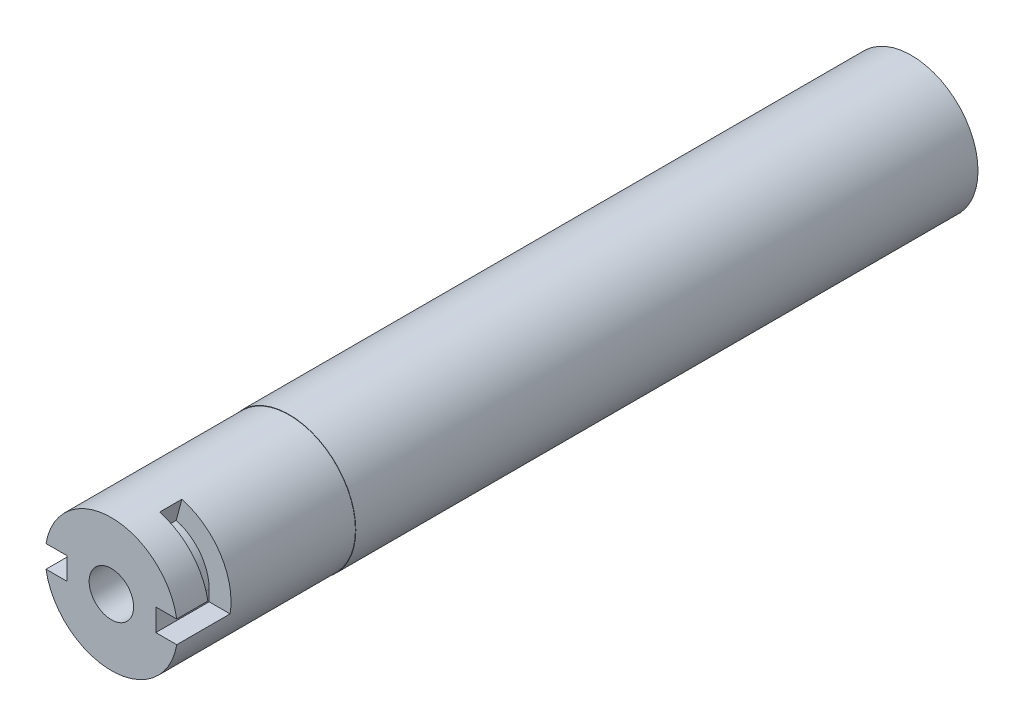
from build123d import *

# Parameters (mm, degrees)
SKETCH1_R           = 9.525
BOSS_EXTRUDE1_DEPTH = 114.3
SKETCH2_R           = 5.55625
CUT_EXTRUDE1_DEPTH  = 101.6
SKETCH3_R           = 3.175
CUT_EXTRUDE2_DEPTH  = 114.3
CUT_EXTRUDE8_DEPTH  = 7.62
CUT_REVOLVE1_ANGLE  = 75
SKETCH8_R           = 9.525
SKETCH8_R_2         = 9.4742
CUT_EXTRUDE10_DEPTH = 25.4


with BuildPart() as part:
    # Sketch1 → Boss-Extrude1 (new body)
    with BuildSketch(Plane.XY):
        Circle(SKETCH1_R)
    extrude(amount=BOSS_EXTRUDE1_DEPTH)

    # Sketch2 → Cut-Extrude1 (cut)
    with BuildSketch(Plane(origin=(0, 0, 0), x_dir=(-1, 0, 0), z_dir=(0, 0, -1))):
        Circle(SKETCH2_R)
    extrude(amount=-CUT_EXTRUDE1_DEPTH, mode=Mode.SUBTRACT)

    # Sketch3 → Cut-Extrude2 (cut)
    with BuildSketch(Plane.XY.offset(114.3)):
        Circle(SKETCH3_R)
    extrude(amount=-CUT_EXTRUDE2_DEPTH, mode=Mode.SUBTRACT)

    # Sketch5 → Cut-Extrude8 (cut)
    with BuildSketch(Plane.XY.offset(114.3)):
        with BuildLine():
            ThreePointArc((9.525, 0), (9.49163573, 0.796540129), (9.391776656, 1.5875))
            Line((9.391776656, 1.5875), (6.35, 1.5875))
            Line((6.35, 1.5875), (6.35, -1.5875))
            Line((6.35, -1.5875), (9.391776656, -1.5875))
            ThreePointArc((9.391776656, -1.5875), (9.49163573, -0.796540129), (9.525, 0))
        make_face()
        with BuildLine():
            Line((-6.35, 1.5875), (-9.391776656, 1.5875))
            ThreePointArc((-9.391776656, 1.5875), (-9.525, 0), (-9.391776656, -1.5875))
            Line((-9.391776656, -1.5875), (-6.35, -1.5875))
            Line((-6.35, -1.5875), (-6.35, 1.5875))
        make_face()
    extrude(amount=-CUT_EXTRUDE8_DEPTH, mode=Mode.SUBTRACT)

    # Sketch7 → Cut-Revolve1 (revolve, cut)
    with BuildSketch(Plane(origin=(0, 0, 0), x_dir=(1, 0, 0), z_dir=(0, 1, 0))):
        Polygon((9.391776656, -106.68), (6.35, -106.68), (6.35, -109.855), (9.525, -109.855), (9.525, -106.68), align=None)
        Polygon((-6.35, -109.855), (-9.525, -109.855), (-9.525, -106.68), (-9.391776656, -106.68), (-6.35, -106.68), align=None)
    revolve(axis=Axis((0, 0, 0), (0, 0, 1)), revolution_arc=CUT_REVOLVE1_ANGLE, mode=Mode.SUBTRACT)

    # Sketch8 → Cut-Extrude10 (cut)
    with BuildSketch(Plane.XY.offset(114.3)):
        Circle(SKETCH8_R)
        Circle(SKETCH8_R_2, mode=Mode.SUBTRACT)
    extrude(amount=-CUT_EXTRUDE10_DEPTH, mode=Mode.SUBTRACT)


solid = part.part
